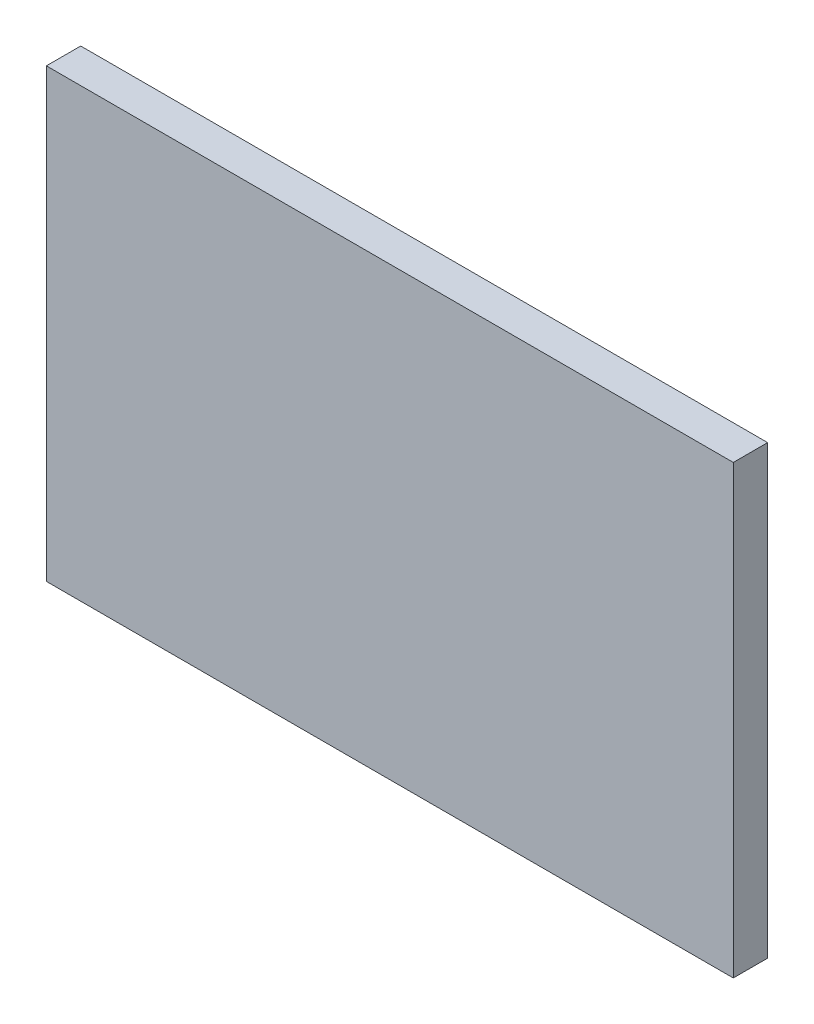
from build123d import *

# Parameters (mm, degrees)
SKETCH1_W           = 200
SKETCH1_H           = 100
BOSS_EXTRUDE1_DEPTH = 10
SKETCH2_W           = 40
SKETCH2_H           = 10
SKETCH2_W_2         = 10
SKETCH2_H_2         = 40
BOSS_EXTRUDE2_DEPTH = 40
SKETCH4_R           = 5
CUT_EXTRUDE2_DEPTH  = 31
SKETCH7_W           = 200
SKETCH7_H           = 10
BOSS_EXTRUDE3_DEPTH = 65
SKETCH9_R           = 5
CUT_EXTRUDE4_DEPTH  = 130


with BuildPart() as part:
    # Sketch1 → Boss-Extrude1 (new body)
    with BuildSketch(Plane.XY):
        Rectangle(SKETCH1_W, SKETCH1_H)
    extrude(amount=BOSS_EXTRUDE1_DEPTH)

    # Sketch2 → Boss-Extrude2 (add)
    with BuildSketch(Plane(origin=(0, 0, 0), x_dir=(-1, 0, 0), z_dir=(0, 0, -1))):
        with Locations((14, 0)):
            Rectangle(SKETCH2_W, SKETCH2_H)
        with Locations((95, 0)):
            Rectangle(SKETCH2_W_2, SKETCH2_H_2)
    extrude(amount=BOSS_EXTRUDE2_DEPTH)

    # Sketch4 → Cut-Extrude2 (cut)
    with BuildSketch(Plane.ZY.offset(100)):
        with Locations((-20, 0)):
            Circle(SKETCH4_R)
    extrude(amount=-CUT_EXTRUDE2_DEPTH, mode=Mode.SUBTRACT)

    # Sketch7 → Boss-Extrude3 (add, symmetric)
    with BuildSketch(Plane(origin=(0, 0, 0), x_dir=(1, 0, 0), z_dir=(0, 1, 0))):
        with Locations((0, -5)):
            Rectangle(SKETCH7_W, SKETCH7_H)
    extrude(amount=BOSS_EXTRUDE3_DEPTH, both=True)

    # Sketch9 → Cut-Extrude4 (cut)
    with BuildSketch(Plane(origin=(0, 5, 0), x_dir=(1, 0, 0), z_dir=(0, 1, 0))):
        with Locations((-14, 20)):
            Circle(SKETCH9_R)
    extrude(amount=-CUT_EXTRUDE4_DEPTH, mode=Mode.SUBTRACT)


solid = part.part
